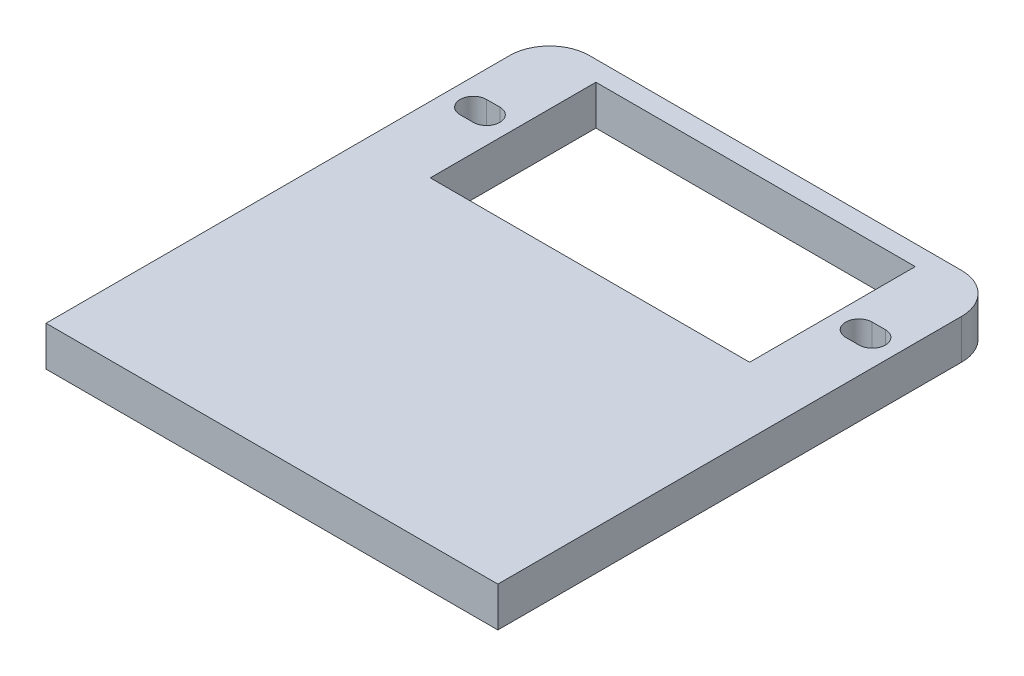
from build123d import *

# Parameters (mm, degrees)
BOSS_EXTRU_1_DEPTH = 3
CONG_1_R           = 3
CONG_2_R           = 3


with BuildPart() as part:
    # Esquisse1 → Boss.-Extru.1 (new body)
    with BuildSketch(Plane(origin=(0, 0, 0), x_dir=(1, 0, 0), z_dir=(0, 1, 0))):
        Polygon((-12.05, 36.5), (0, 36.5), (0, 38), (-17.05, 38), (-17.05, 0), (0, 0), (0, 24), (-12.05, 24), align=None)
        with BuildLine():
            ThreePointArc((-15.05, 29.25), (-16.05, 30.25), (-15.05, 31.25))
            Line((-15.05, 31.25), (-14.05, 31.25))
            ThreePointArc((-14.05, 31.25), (-13.05, 30.25), (-14.05, 29.25))
            Line((-14.05, 29.25), (-15.05, 29.25))
        make_face(mode=Mode.SUBTRACT)
    boss_extru_1 = extrude(amount=BOSS_EXTRU_1_DEPTH)

    # Symétrie1: Boss.-Extru.1 across plane
    add(boss_extru_1.mirror(Plane(origin=(0, 3, 0), x_dir=(0, 0, 1), z_dir=(-1, 0, 0))))

    # Congé1
    cong_1_edges = [part.edges().sort_by_distance(p)[0] for p in [
        (17.05, 1.5, -38),
    ]]
    fillet(cong_1_edges, radius=CONG_1_R)

    # Congé2
    cong_2_edges = [part.edges().sort_by_distance(p)[0] for p in [
        (-17.05, 1.5, -38),
    ]]
    fillet(cong_2_edges, radius=CONG_2_R)


solid = part.part
